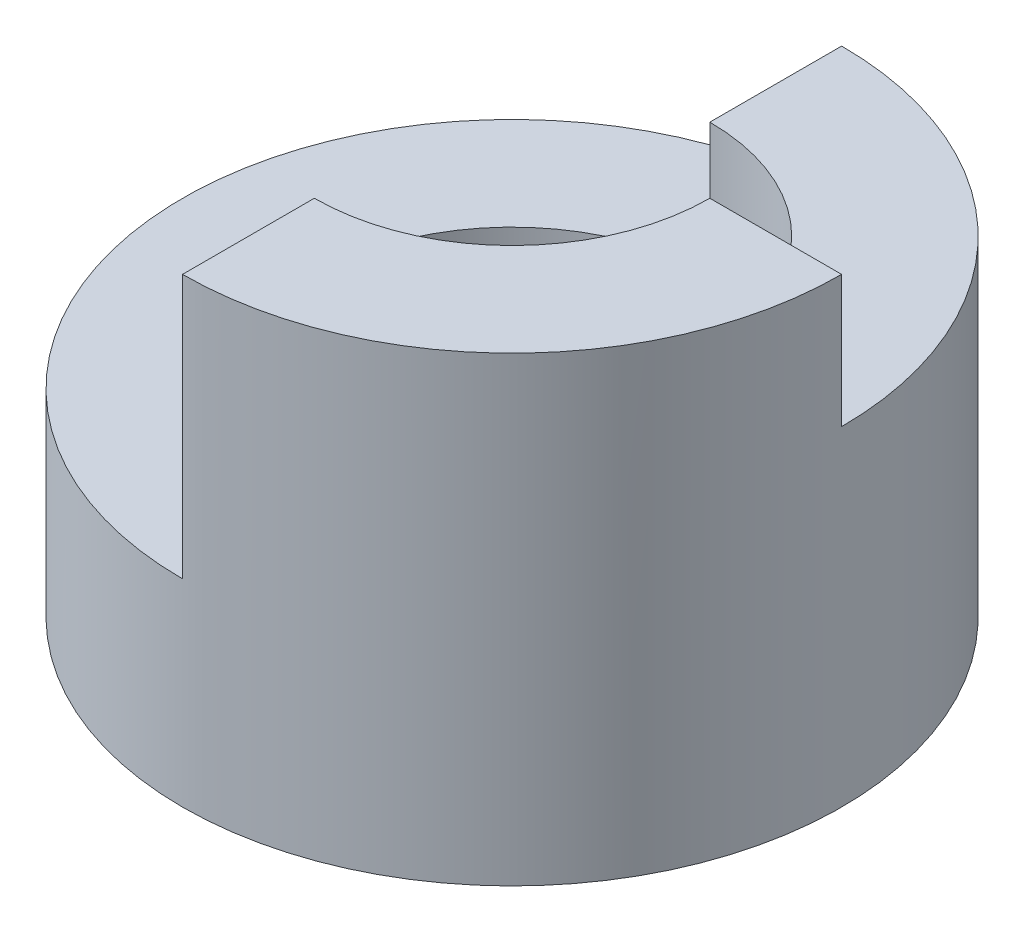
from build123d import *

# Parameters (mm, degrees)
SKETCH1_R           = 5
SKETCH1_R_2         = 3
BOSS_EXTRUDE1_DEPTH = 7
SKETCH3_W           = 6.288888245
SKETCH3_H           = 10.422150442
CUT_EXTRUDE1_DEPTH  = 4
SKETCH4_W           = 5
SKETCH4_H           = 5
CUT_EXTRUDE2_DEPTH  = 2


with BuildPart() as part:
    # Sketch1 → Boss-Extrude1 (new body)
    with BuildSketch(Plane(origin=(0, 0, 0), x_dir=(1, 0, 0), z_dir=(0, 1, 0))):
        Circle(SKETCH1_R)
        Circle(SKETCH1_R_2, mode=Mode.SUBTRACT)
    extrude(amount=BOSS_EXTRUDE1_DEPTH)

    # Sketch3 → Cut-Extrude1 (cut)
    with BuildSketch(Plane(origin=(0, 7, 0), x_dir=(1, 0, 0), z_dir=(0, 1, 0))):
        with Locations((-3.144444123, -0.211075221)):
            Rectangle(SKETCH3_W, SKETCH3_H)
    extrude(amount=-CUT_EXTRUDE1_DEPTH, mode=Mode.SUBTRACT)

    # Sketch4 → Cut-Extrude2 (cut)
    with BuildSketch(Plane(origin=(0, 7, 0), x_dir=(1, 0, 0), z_dir=(0, 1, 0))):
        with Locations((2.5, 2.5)):
            Rectangle(SKETCH4_W, SKETCH4_H)
    extrude(amount=-CUT_EXTRUDE2_DEPTH, mode=Mode.SUBTRACT)


solid = part.part
